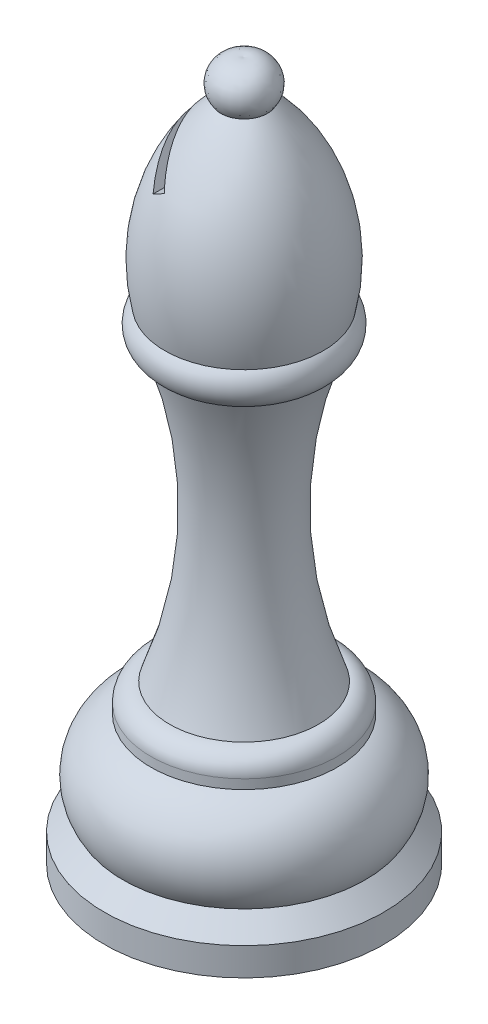
from build123d import *

# Parameters (mm, degrees)
CUT_EXTRUDE1_DEPTH      = 16
CUT_EXTRUDE1_DEPTH_BACK = 16


with BuildPart() as part:
    # Sketch1 → Revolve1 (revolve)
    with BuildSketch(Plane.XY):
        with BuildLine():
            Line((0, 0), (-15, 0))
            Line((-15, 0), (-15, 3))
            Line((-15, 3), (-13, 5))
            ThreePointArc((-13, 5), (-13.688325627, 10.216881481), (-10, 13.97))
            Line((-10, 13.97), (-10, 14.97))
            ThreePointArc((-10, 14.97), (-9.414213562, 16.384213562), (-8, 16.97))
            ThreePointArc((-8, 16.97), (-4.992249752, 32.435548835), (-7.5, 47.99))
            ThreePointArc((-7.5, 47.99), (-9.185787897, 49.659038605), (-8.5, 51.93))
            ThreePointArc((-8.5, 51.93), (-8.050914733, 62.26301618), (-2.5, 70.99))
            ThreePointArc((-2.5, 70.99), (-2.678187953, 73.885391492), (0, 75))
            Line((0, 75), (0, 70.99))
            Line((0, 70.99), (0, 51.93))
            Line((0, 51.93), (0, 47.99))
            Line((0, 47.99), (0, 16.97))
            Line((0, 16.97), (0, 14.97))
            Line((0, 14.97), (0, 13.97))
            Line((0, 13.97), (0, 5))
            Line((0, 5), (0, 3))
            Line((0, 3), (0, 0))
        make_face()
    revolve(axis=Axis((0, 0, 0), (0, 1, 0)))

    # Sketch2 → Cut-Extrude1 (cut, two sides)
    with BuildSketch(Plane.XY) as cut_extrude1_sk:
        Polygon((-4.249702272, 69.166839221), (-1.749702272, 64.836712202), (-3.048740377, 64.086712202), (-5.243895878, 67.888833061), (-5.823762224, 68.893191032), (-4.631125277, 69.887003162), align=None)
    extrude(amount=CUT_EXTRUDE1_DEPTH, mode=Mode.SUBTRACT)
    extrude(cut_extrude1_sk.sketch, amount=-CUT_EXTRUDE1_DEPTH_BACK, mode=Mode.SUBTRACT)


solid = part.part
